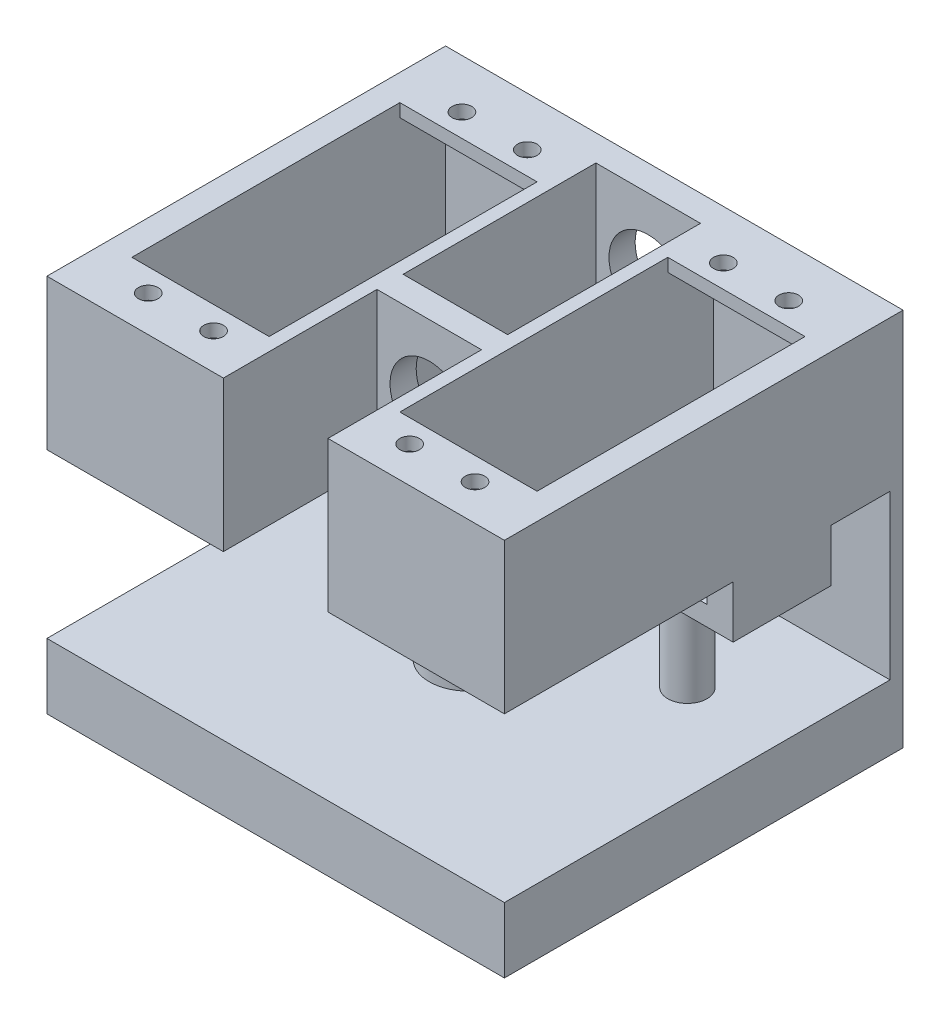
from build123d import *

# Parameters (mm, degrees)
EXTRUDE_1_DEPTH     = 23
EXTRUDE_1_2_DEPTH   = 23
SKETCH_2_W          = 21
SKETCH_2_H          = 9
EXTRUDE_2_DEPTH     = 2
SKETCH_3_R          = 1.5
CUT_EXTRUDE_1_DEPTH = 2
SKETCH_4_W          = 4.5
SKETCH_4_H          = 23
EXTRUDE_3_DEPTH     = 20
SKETCH_5_W          = 20
SKETCH_5_H          = 23
EXTRUDE_4_DEPTH     = 54.5
SKETCH_7_R          = 6
EXTRUDE_5_DEPTH     = 35
SKETCH_8_W          = 4
SKETCH_8_H          = 15
EXTRUDE_6_DEPTH     = 5
EXTRUDE_7_DEPTH     = 3
SKETCH_10_R         = 5
EXTRUDE_8_DEPTH     = 35
EXTRUDE_9_DEPTH     = 35
SKETCH_12_R         = 3
EXTRUDE_10_DEPTH    = 27
CUT_EXTRUDE_2_DEPTH = 27
CUT_EXTRUDE_3_DEPTH = 20
EXTRUDE_11_DEPTH    = 2
SKETCH_16_W         = 35
SKETCH_16_H         = 27
CUT_EXTRUDE_5_DEPTH = 2
SKETCH_18_W         = 16
SKETCH_18_H         = 2
CUT_EXTRUDE_7_DEPTH = 30
SKETCH_19_R         = 3
CUT_EXTRUDE_8_DEPTH = 50
EXTRUDE_12_DEPTH    = 10
SKETCH_21_R         = 6
CUT_EXTRUDE_9_DEPTH = 60


with BuildPart() as part:
    # 스케치1 → 보스-돌출1 (new body)
    with BuildSketch(Plane(origin=(0, 0, 0), x_dir=(1, 0, 0), z_dir=(0, 1, 0))):
        Polygon((-66, 57), (-45, 57), (-45, 59), (-70, 59), (-70, 0), (-45, 0), (-45, 2), (-66, 2), align=None)
    extrude(amount=EXTRUDE_1_DEPTH)



with BuildPart() as body_2:
    # 스케치1 → Extrude 1 2 (new body)
    with BuildSketch(Plane(origin=(0, 0, 0), x_dir=(1, 0, 0), z_dir=(0, 1, 0))):
        Polygon((-25, 2), (-4, 2), (-4, 57), (-25, 57), (-25, 59), (0, 59), (0, 0), (-25, 0), align=None)
    extrude(amount=EXTRUDE_1_2_DEPTH)


with BuildPart() as part_1:
    add(part.part)

    add(body_2.part)  # 보스-돌출2 merges body 2
    # 스케치2 → 보스-돌출2 (add)
    with BuildSketch(Plane(origin=(0, 23, 0), x_dir=(1, 0, 0), z_dir=(0, 1, 0))):
        with Locations((-55.5, 54.5)):
            Rectangle(SKETCH_2_W, SKETCH_2_H)
        with Locations((-14.5, 54.5)):
            Rectangle(SKETCH_2_W, SKETCH_2_H)
        with Locations((-55.5, 4.5)):
            Rectangle(SKETCH_2_W, SKETCH_2_H)
        with Locations((-14.5, 4.5)):
            Rectangle(SKETCH_2_W, SKETCH_2_H)
    extrude(amount=-EXTRUDE_2_DEPTH)

    # 스케치3 → 컷-돌출1 (cut)
    with BuildSketch(Plane(origin=(0, 23, 0), x_dir=(1, 0, 0), z_dir=(0, 1, 0))):
        with Locations((-50, 53.5)):
            Circle(SKETCH_3_R)
        with Locations((-60, 53.5)):
            Circle(SKETCH_3_R)
        with Locations((-20, 53.5)):
            Circle(SKETCH_3_R)
        with Locations((-10, 53.5)):
            Circle(SKETCH_3_R)
        with Locations((-60, 5.5)):
            Circle(SKETCH_3_R)
        with Locations((-50, 5.5)):
            Circle(SKETCH_3_R)
        with Locations((-20, 5.5)):
            Circle(SKETCH_3_R)
        with Locations((-10, 5.5)):
            Circle(SKETCH_3_R)
    extrude(amount=-CUT_EXTRUDE_1_DEPTH, mode=Mode.SUBTRACT)

    # 스케치4 → 보스-돌출3 (add)
    with BuildSketch(Plane.ZY.offset(25)):
        with Locations((-56.75, 11.5)):
            Rectangle(SKETCH_4_W, SKETCH_4_H)
    extrude(amount=EXTRUDE_3_DEPTH)

    # 스케치5 → 보스-돌출4 (add)
    with BuildSketch(Plane.XY.offset(-54.5)):
        with Locations((-35, 11.5)):
            Rectangle(SKETCH_5_W, SKETCH_5_H)
    extrude(amount=EXTRUDE_4_DEPTH)

    # 스케치7 → 보스-돌출5 (add)
    with BuildSketch(Plane.XZ):
        with Locations((-35, -29.5)):
            Circle(SKETCH_7_R)
    extrude(amount=EXTRUDE_5_DEPTH)

    # 스케치8 → 보스-돌출6 (add)
    with BuildSketch(Plane.XZ):
        with Locations((-2, -42.5)):
            Rectangle(SKETCH_8_W, SKETCH_8_H)
        with Locations((-68, -42.5)):
            Rectangle(SKETCH_8_W, SKETCH_8_H)
    extrude(amount=EXTRUDE_6_DEPTH)

    # 스케치9 → 보스-돌출7 (add)
    with BuildSketch(Plane.XZ.offset(5)):
        Polygon((-70, -50), (-45, -50), (0, -50), (0, -35), (-70, -35), align=None)
    extrude(amount=EXTRUDE_7_DEPTH)

    # 스케치10 → 보스-돌출8 (add)
    with BuildSketch(Plane.XZ):
        with Locations((-35, -42.5)):
            Circle(SKETCH_10_R)
    extrude(amount=EXTRUDE_8_DEPTH)

    # 스케치11 → 보스-돌출9 (add)
    with BuildSketch(Plane.XZ.offset(35)):
        Polygon((-35, -29.5), (-33, -29.5), (-33, -42.5), (-37, -42.5), (-37, -29.5), align=None)
    extrude(amount=-EXTRUDE_9_DEPTH)

    # 스케치12 → 보스-돌출10 (add)
    with BuildSketch(Plane.XZ.offset(8)):
        with Locations((-55.5, -42.5)):
            Circle(SKETCH_12_R)
        with Locations((-14.5, -42.5)):
            Circle(SKETCH_12_R)
    extrude(amount=EXTRUDE_10_DEPTH)

    # 스케치13 → 컷-돌출2 (cut)
    with BuildSketch(Plane.XZ):
        Polygon((-35, -23.5), (-27, -23.5), (-27, -2), (-43, -2), (-43, -23.5), align=None)
    extrude(amount=-CUT_EXTRUDE_2_DEPTH, mode=Mode.SUBTRACT)

    # 스케치14 → 컷-돌출3 (cut)
    with BuildSketch(Plane(origin=(0, 23, 0), x_dir=(1, 0, 0), z_dir=(0, 1, 0))):
        Polygon((-27, 57), (-35, 57), (-43, 57), (-43, 27.5), (-35, 27.5), (-27, 27.5), align=None)
    extrude(amount=-CUT_EXTRUDE_3_DEPTH, mode=Mode.SUBTRACT)

    # 스케치15 → 보스-돌출11 (add)
    with BuildSketch(Plane(origin=(0, 0, -59), x_dir=(-1, 0, 0), z_dir=(0, 0, -1))):
        Polygon((0, 0), (0, 23), (70, 23), (70, -35), (0, -35), align=None)
    extrude(amount=EXTRUDE_11_DEPTH)

    # 스케치16 → 컷-돌출5 (cut)
    with BuildSketch(Plane.XY.offset(-59)):
        with Locations((-35, -21.5)):
            Rectangle(SKETCH_16_W, SKETCH_16_H)
    extrude(amount=-CUT_EXTRUDE_5_DEPTH, mode=Mode.SUBTRACT)

    # 스케치18 → 컷-돌출7 (cut)
    with BuildSketch(Plane(origin=(0, 23, 0), x_dir=(1, 0, 0), z_dir=(0, 1, 0))):
        with Locations((-35, 1)):
            Rectangle(SKETCH_18_W, SKETCH_18_H)
    extrude(amount=-CUT_EXTRUDE_7_DEPTH, mode=Mode.SUBTRACT)

    # 스케치19 → 컷-돌출8 (cut)
    with BuildSketch(Plane.XY.offset(-23.5)):
        with Locations((-35, 11.5)):
            Circle(SKETCH_19_R)
    extrude(amount=-CUT_EXTRUDE_8_DEPTH, mode=Mode.SUBTRACT)

    # 스케치20 → 보스-돌출12 (add)
    with BuildSketch(Plane.XZ.offset(35)):
        Polygon((-35, 0), (0, 0), (0, -61), (-70, -61), (-70, 0), align=None)
    extrude(amount=-EXTRUDE_12_DEPTH)

    # 스케치21 → 컷-돌출9 (cut)
    with BuildSketch(Plane.XY.offset(-23.5)):
        with Locations((-35, 11.5)):
            Circle(SKETCH_21_R)
    extrude(amount=-CUT_EXTRUDE_9_DEPTH, mode=Mode.SUBTRACT)


solid = part_1.part
